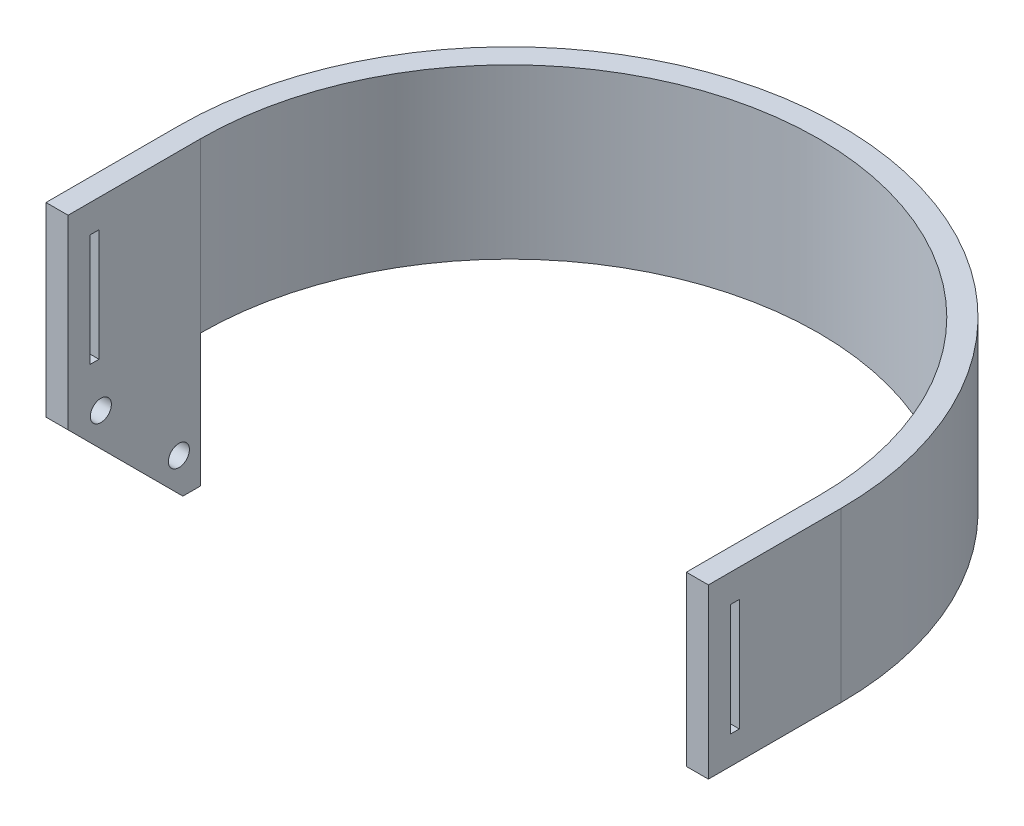
from build123d import *

# Parameters (mm, degrees)
SKETCH1_W           = 5
SKETCH1_H           = 30
BOSS_EXTRUDE1_DEPTH = 38.1
SKETCH2_W           = 2
SKETCH2_H           = 25.4
CUT_EXTRUDE1_DEPTH  = 151
BOSS_EXTRUDE3_DEPTH = 150
CUT_EXTRUDE2_START  = -145
SKETCH4_W           = 32.727499149
SKETCH4_H           = 37.13145561
CUT_EXTRUDE2_DEPTH  = 145


with BuildPart() as part:
    # Sketch1 → Boss-Extrude1 (new body)
    with BuildSketch(Plane(origin=(0, 0, 0), x_dir=(1, 0, 0), z_dir=(0, 1, 0))):
        with Locations((-72.5, -15)):
            Rectangle(SKETCH1_W, SKETCH1_H)
        with BuildLine():
            ThreePointArc((75, 0), (0, 75), (-75, 0))
            Line((-75, 0), (-70, 0))
            ThreePointArc((-70, 0), (0, 70), (70, 0))
            Line((70, 0), (75, 0))
        make_face()
        with Locations((72.5, -15)):
            Rectangle(SKETCH1_W, SKETCH1_H)
    extrude(amount=BOSS_EXTRUDE1_DEPTH)

    # Sketch2 → Cut-Extrude1 (cut, through all)
    with BuildSketch(Plane(origin=(75, 0, 0), x_dir=(0, 0, -1), z_dir=(1, 0, 0))):
        with Locations((-24, 19.05)):
            Rectangle(SKETCH2_W, SKETCH2_H)
    extrude(amount=-CUT_EXTRUDE1_DEPTH, mode=Mode.SUBTRACT)

    # Sketch3 → Boss-Extrude3 (add)
    with BuildSketch(Plane(origin=(75, 0, 0), x_dir=(0, 0, -1), z_dir=(1, 0, 0))):
        Polygon((0, -30), (-30, 0), (-30, -4), (-4, -30), align=None)
        with BuildLine():
            Line((-26.464466094, 0), (-30, 0))
            Line((-30, 0), (0, -30))
            Line((0, -30), (0, -26.464466094))
            Line((0, -26.464466094), (-3.213911245, -23.250554849))
            ThreePointArc((-3.213911245, -23.250554849), (-6.581507291, -23.250554849), (-6.581507291, -19.882958803))
            Line((-6.581507291, -19.882958803), (-20.891580775, -5.572885319))
            ThreePointArc((-20.891580775, -5.572885319), (-24.25917682, -5.572885319), (-24.25917682, -2.205289274))
            Line((-24.25917682, -2.205289274), (-26.464466094, 0))
        make_face()
        with BuildLine():
            Line((-22.928932188, 0), (-26.464466094, 0))
            Line((-26.464466094, 0), (-24.25917682, -2.205289274))
            ThreePointArc((-24.25917682, -2.205289274), (-21.664113874, -1.68909916), (-20.194128798, -3.889087297))
            ThreePointArc((-20.194128798, -3.889087297), (-20.375390661, -4.80035222), (-20.891580775, -5.572885319))
            Line((-20.891580775, -5.572885319), (-6.581507291, -19.882958803))
            ThreePointArc((-6.581507291, -19.882958803), (-3.986444345, -19.366768689), (-2.516459268, -21.566756826))
            ThreePointArc((-2.516459268, -21.566756826), (-2.697721131, -22.47802175), (-3.213911245, -23.250554849))
            Line((-3.213911245, -23.250554849), (0, -26.464466094))
            Line((0, -26.464466094), (0, -22.928932188))
            Line((0, -22.928932188), (-22.928932188, 0))
        make_face()
        Polygon((0, 0), (-22.928932188, 0), (0, -22.928932188), align=None)
    extrude(amount=-BOSS_EXTRUDE3_DEPTH)

    # Sketch4 → Cut-Extrude2 (cut)
    with BuildSketch(Plane(origin=(75, 0, 0), x_dir=(0, 0, -1), z_dir=(1, 0, 0)).offset(CUT_EXTRUDE2_START)):
        with Locations((-16.363749575, -18.565727805)):
            Rectangle(SKETCH4_W, SKETCH4_H)
    extrude(amount=CUT_EXTRUDE2_DEPTH, mode=Mode.SUBTRACT)


solid = part.part
